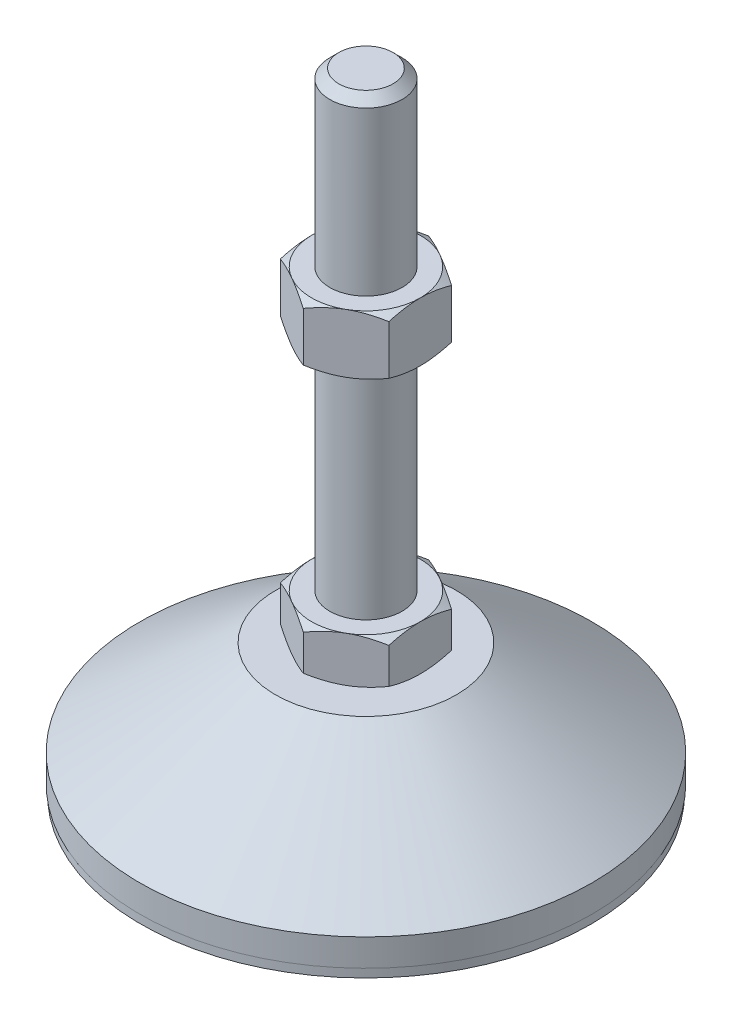
from build123d import *

# Parameters (mm, degrees)
EXTRUDE_1_DEPTH = 10
EXTRUDE_2_DEPTH = 13


with BuildPart() as part:
    # Эскиз1 → Повернуть1 (revolve)
    with BuildSketch(Plane.XY, mode=Mode.PRIVATE) as revolve_1_sk:
        Polygon((0, 0), (-49.8, 0), (-49.8, 2), (-50, 2), (-50, 8), (-20, 29), (-8, 29), (-8, 39), (-8, 137), (-6, 139), (0, 139), align=None)
    revolve(revolve_1_sk.sketch.rotate(Axis((0, 0, 0), (0, 1, 0)), 180), axis=Axis((0, 0, 0), (0, 1, 0)))  # turned: the seam where the file's is

    # Эскиз2 → Бобышка-Вытянуть1 (add)
    with BuildSketch(Plane(origin=(0, 29, 0), x_dir=(1, 0, 0), z_dir=(0, 1, 0))):
        Polygon((0, 13.856406461), (-12, 6.92820323), (-12, -6.92820323), (0, -13.856406461), (12, -6.92820323), (12, 6.92820323), align=None)
    extrude(amount=EXTRUDE_1_DEPTH)

    # Эскиз3 → Бобышка-Вытянуть2 (add)
    with BuildSketch(Plane(origin=(0, 88, 0), x_dir=(1, 0, 0), z_dir=(0, 1, 0))):
        Polygon((12, 6.92820323), (0, 13.856406461), (-12, 6.92820323), (-12, -6.92820323), (0, -13.856406461), (12, -6.92820323), align=None)
    extrude(amount=EXTRUDE_2_DEPTH)

    # Эскиз4 → Вырез-Повернуть2 (revolve, cut)
    with BuildSketch(Plane.XY, mode=Mode.PRIVATE) as cut_revolve_2_sk:
        Polygon((-23.258330249, 101), (-12, 101), (-23.258330249, 94.5), align=None)
        Polygon((-23.258330249, 88), (-23.258330249, 94.5), (-12, 88), align=None)
        Polygon((-20.660254038, 39), (-20.660254038, 34), (-12, 39), align=None)
        Polygon((-20.660254038, 34), (-20.660254038, 29), (-12, 29), align=None)
    revolve(cut_revolve_2_sk.sketch.rotate(Axis((0, 139, 0), (0, -1, 0)), 180), axis=Axis((0, 139, 0), (0, -1, 0)), mode=Mode.SUBTRACT)  # turned: the seam where the file's is


solid = part.part
